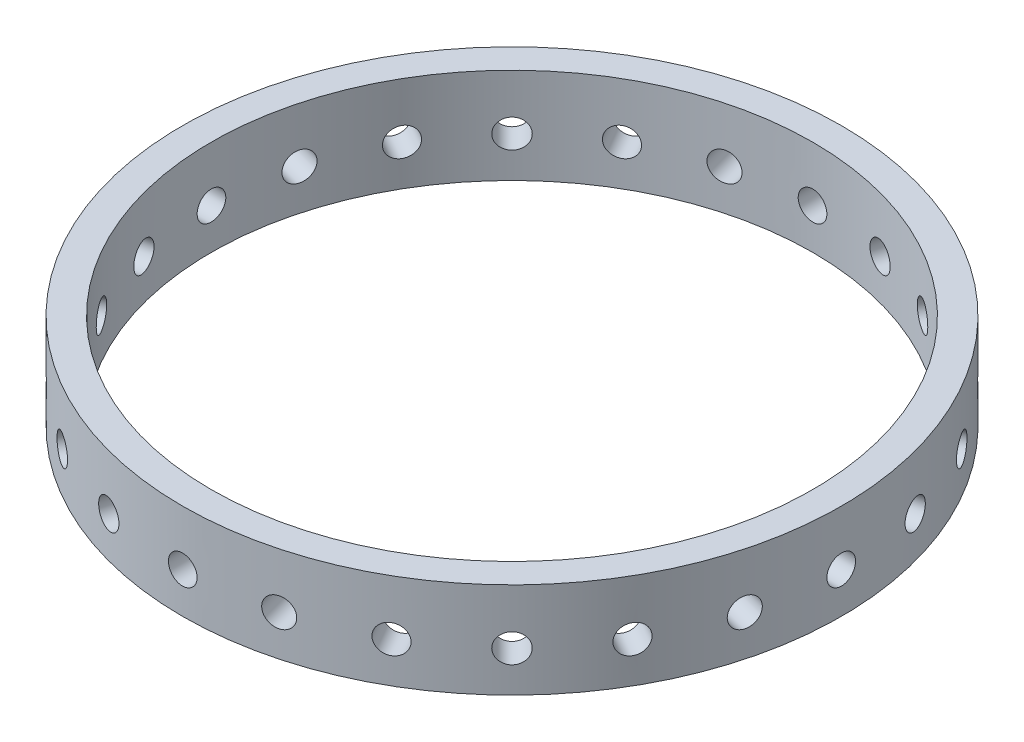
from build123d import *

# Parameters (mm, degrees)
SKETCH1_R           = 69
SKETCH1_R_2         = 63
BOSS_EXTRUDE1_DEPTH = 20
SKETCH5_R           = 3
CUT_EXTRUDE1_DEPTH  = 84
CIRPATTERN1_COUNT   = 24


with BuildPart() as part:
    # Sketch1 → Boss-Extrude1 (new body)
    with BuildSketch(Plane(origin=(0, 0, 0), x_dir=(1, 0, 0), z_dir=(0, 1, 0))):
        Circle(SKETCH1_R)
        Circle(SKETCH1_R_2, mode=Mode.SUBTRACT)
    extrude(amount=BOSS_EXTRUDE1_DEPTH)

    # Sketch5 → Cut-Extrude1 (cut)
    with BuildSketch(Plane.XY):
        with Locations((0, 8.5)):
            Circle(SKETCH5_R)
    cut_extrude1 = extrude(amount=-CUT_EXTRUDE1_DEPTH, mode=Mode.SUBTRACT)

    # CirPattern1: Cut-Extrude1 ×24 about axis
    cirpattern1_axis = Axis((0, 21, 0), (0, -1, 0))
    for i in range(1, CIRPATTERN1_COUNT):
        add(cut_extrude1.rotate(cirpattern1_axis, i * 360 / CIRPATTERN1_COUNT), mode=Mode.SUBTRACT)


solid = part.part
